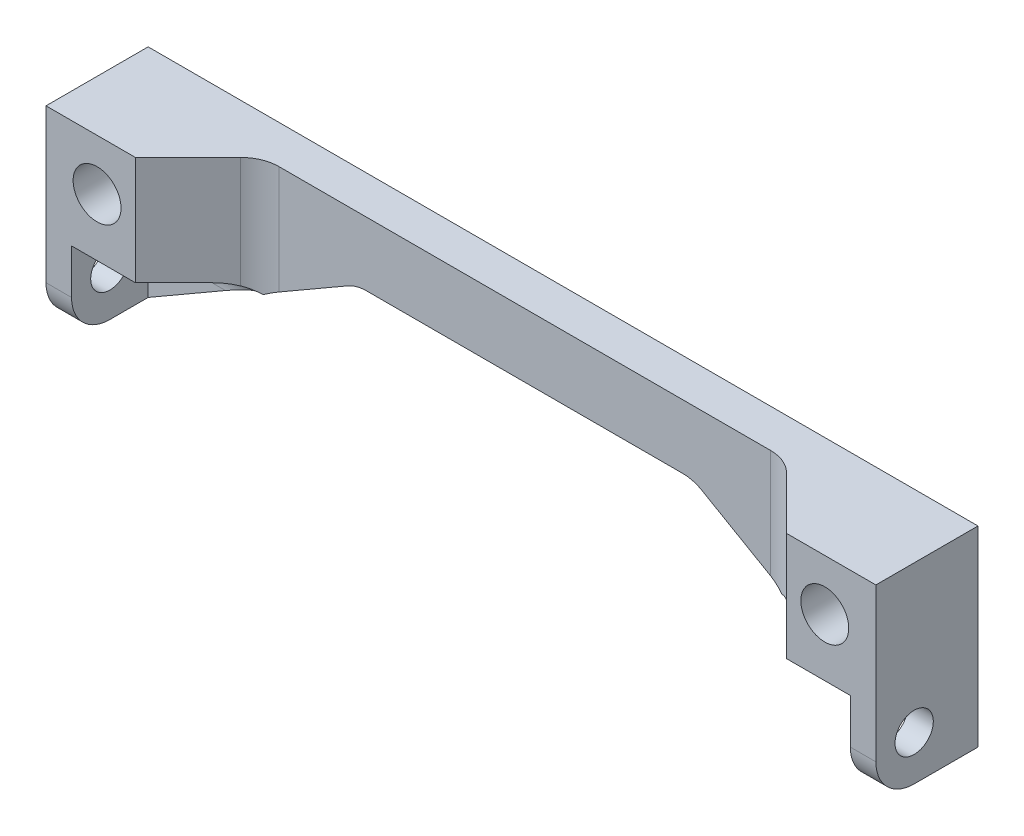
from build123d import *

# Parameters (mm, degrees)
SKETCH2_R           = 3.75
BOSS_EXTRUDE1_DEPTH = 16
SKETCH3_R           = 3
CUT_EXTRUDE1_DEPTH  = 131
CUT_EXTRUDE2_DEPTH  = 31
CUT_EXTRUDE3_START  = -4
CUT_EXTRUDE3_DEPTH  = 30
CUT_EXTRUDE4_START  = -4
CUT_EXTRUDE4_DEPTH  = 30
FILLET1_R           = 6


with BuildPart() as part:
    # Sketch2 → Boss-Extrude1 (new body)
    with BuildSketch(Plane.XY):
        Polygon((-65, 0), (65, 0), (65, -30), (61, -30), (26.358983849, -10), (-26.358983849, -10), (-61, -30), (-65, -30), align=None)
        with Locations((-57, -8)):
            Circle(SKETCH2_R, mode=Mode.SUBTRACT)
        with Locations((57, -8)):
            Circle(SKETCH2_R, mode=Mode.SUBTRACT)
    extrude(amount=BOSS_EXTRUDE1_DEPTH)

    # Sketch3 → Cut-Extrude1 (cut, through all)
    with BuildSketch(Plane(origin=(65, 0, 0), x_dir=(0, 0, -1), z_dir=(1, 0, 0))):
        with Locations((-10, -23)):
            Circle(SKETCH3_R)
    extrude(amount=-CUT_EXTRUDE1_DEPTH, mode=Mode.SUBTRACT)

    # Sketch4 → Cut-Extrude2 (cut, through all)
    with BuildSketch(Plane(origin=(0, 0, 0), x_dir=(1, 0, 0), z_dir=(0, 1, 0))):
        Polygon((-51, -16), (-41, -6), (41, -6), (51, -16), align=None)
    extrude(amount=-CUT_EXTRUDE2_DEPTH, mode=Mode.SUBTRACT)

    # Sketch5 → Cut-Extrude3 (cut)
    with BuildSketch(Plane.ZY.offset(65).offset(CUT_EXTRUDE3_START)):
        with BuildLine():
            Line((4, -23), (4, -30))
            Line((4, -30), (16, -30))
            Line((16, -30), (16, -17))
            Line((16, -17), (10, -17))
            ThreePointArc((10, -17), (5.757359313, -18.757359313), (4, -23))
        make_face()
    extrude(amount=-CUT_EXTRUDE3_DEPTH, mode=Mode.SUBTRACT)

    # Sketch6 → Cut-Extrude4 (cut)
    with BuildSketch(Plane(origin=(65, 0, 0), x_dir=(0, 0, -1), z_dir=(1, 0, 0)).offset(CUT_EXTRUDE4_START)):
        with BuildLine():
            Line((-10, -17), (-16, -17))
            Line((-16, -17), (-16, -30))
            Line((-16, -30), (-4, -30))
            Line((-4, -30), (-4, -23))
            ThreePointArc((-4, -23), (-5.757359313, -18.757359313), (-10, -17))
        make_face()
    extrude(amount=-CUT_EXTRUDE4_DEPTH, mode=Mode.SUBTRACT)

    # Fillet1
    fillet1_edges = [part.edges().sort_by_distance(p)[0] for p in [
        (41, -9.226497308, 6),
        (-41, -9.226497308, 6),
        (-26.358983849, -10, 3),
        (26.358983849, -10, 3),
        (63, -30, 16),
        (-63, -30, 16),
    ]]
    fillet(fillet1_edges, radius=FILLET1_R)


solid = part.part
